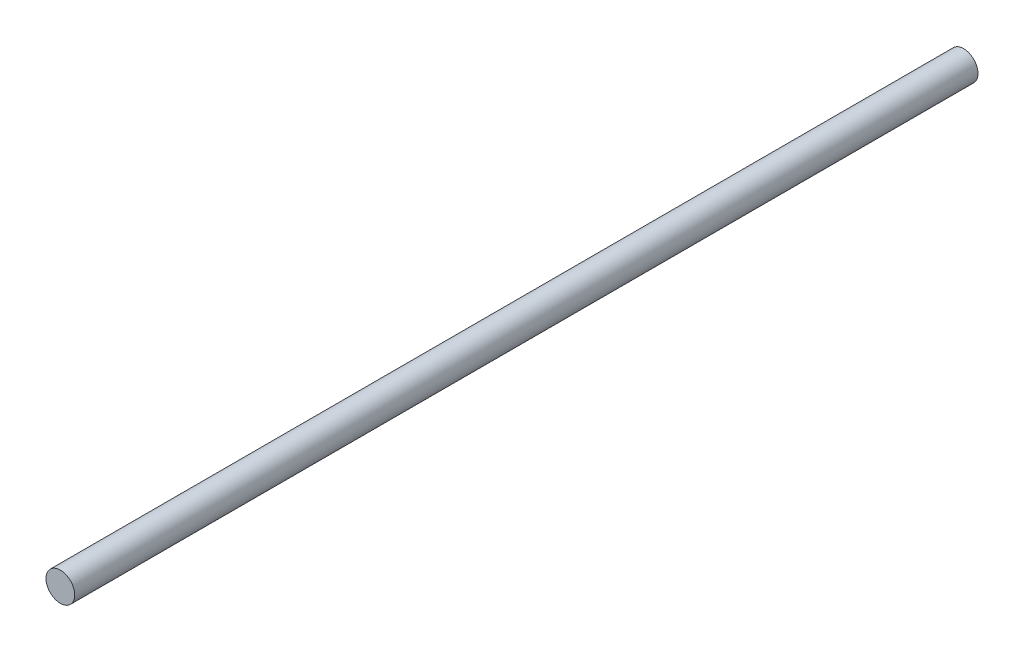
from build123d import *

# Parameters (mm, degrees)
SKETCH1_R           = 8
BOSS_EXTRUDE1_DEPTH = 251


with BuildPart() as part:
    # Sketch1 → Boss-Extrude1 (new body, symmetric)
    with BuildSketch(Plane.XY):
        Circle(SKETCH1_R)
    extrude(amount=BOSS_EXTRUDE1_DEPTH, both=True)


solid = part.part
